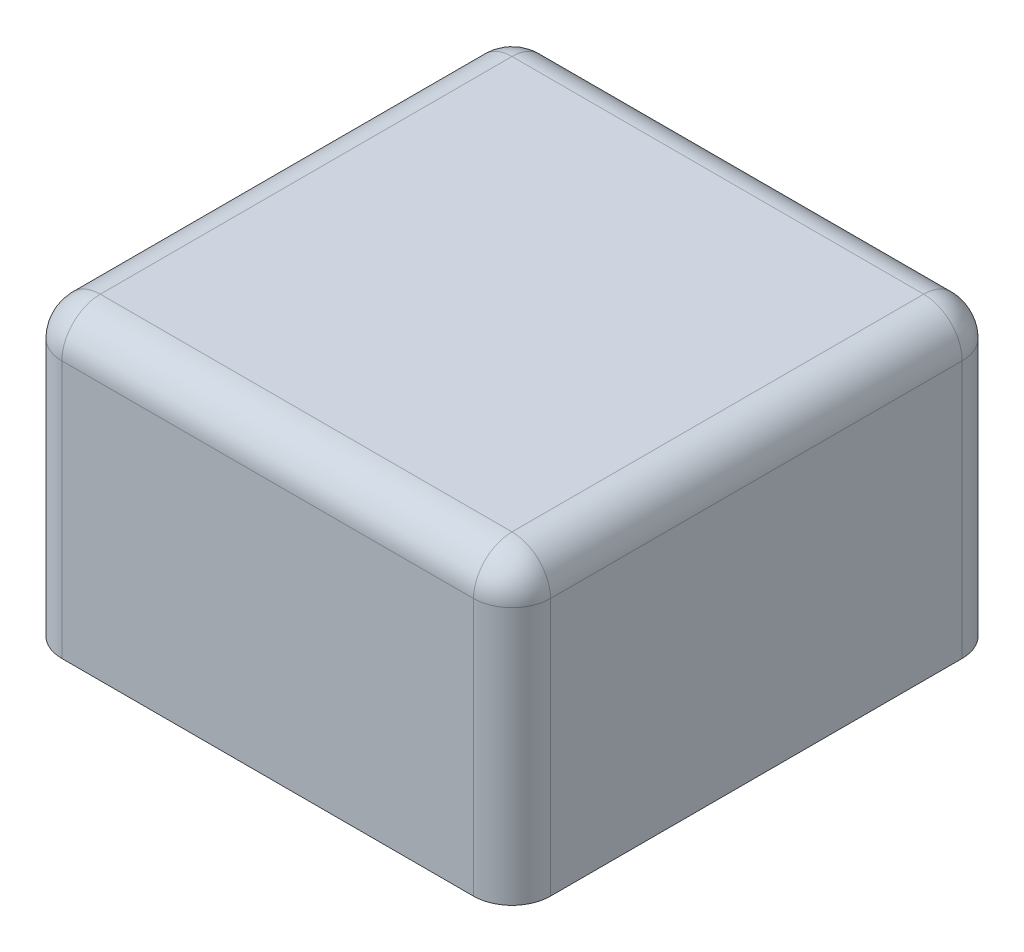
from build123d import *

# Parameters (mm, degrees)
SKETCH1_W           = 25.4
SKETCH1_H           = 25.4
BOSS_EXTRUDE1_DEPTH = 15.4
FILLET1_R           = 2


with BuildPart() as part:
    # Sketch1 → Boss-Extrude1 (new body)
    with BuildSketch(Plane(origin=(0, 0, 0), x_dir=(1, 0, 0), z_dir=(0, 1, 0))):
        Rectangle(SKETCH1_W, SKETCH1_H)
    extrude(amount=BOSS_EXTRUDE1_DEPTH)

    # Fillet1
    fillet1_edges = [part.edges().sort_by_distance(p)[0] for p in [
        (-12.7, 15.4, 0),
        (0, 15.4, 12.7),
        (12.7, 15.4, 0),
        (0, 15.4, -12.7),
        (12.7, 7.7, 12.7),
        (-12.7, 7.7, 12.7),
        (-12.7, 7.7, -12.7),
        (12.7, 7.7, -12.7),
    ]]
    fillet(fillet1_edges, radius=FILLET1_R)


solid = part.part
